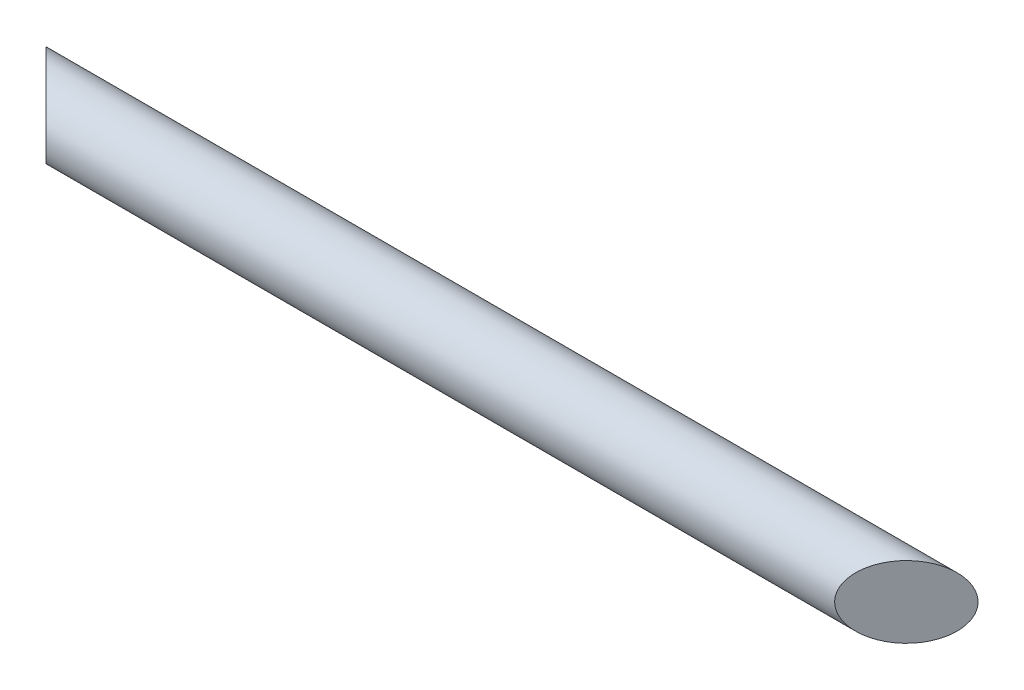
from build123d import *

# Parameters (mm, degrees)
SKETCH1_R           = 31.75
BOSS_EXTRUDE1_DEPTH = 698.5
SKETCH5_R           = 31.75
BOSS_EXTRUDE2_DEPTH = 63.5
SKETCH6_R           = 31.75
BOSS_EXTRUDE3_DEPTH = 63.5
CUT_EXTRUDE1_DEPTH  = 63.5


with BuildPart() as part:
    # Sketch1 → Boss-Extrude1 (new body)
    with BuildSketch(Plane(origin=(0, 0, 0), x_dir=(0, 0, -1), z_dir=(1, 0, 0))):
        Circle(SKETCH1_R)
    extrude(amount=BOSS_EXTRUDE1_DEPTH)

    # Sketch5 → Boss-Extrude2 (add)
    with BuildSketch(Plane.ZY):
        Circle(SKETCH5_R)
    extrude(amount=BOSS_EXTRUDE2_DEPTH)

    # Sketch6 → Boss-Extrude3 (add)
    with BuildSketch(Plane(origin=(698.5, 0, 0), x_dir=(0, 0, -1), z_dir=(1, 0, 0))):
        Circle(SKETCH6_R)
    extrude(amount=BOSS_EXTRUDE3_DEPTH)

    # Sketch7 → Cut-Extrude1 (cut)
    with BuildSketch(Plane(origin=(0, 31.75, 0), x_dir=(1, 0, 0), z_dir=(0, 1, 0))):
        Polygon((0, -31.75), (-63.5, -31.75), (-63.5, 31.75), align=None)
        Polygon((698.5, -31.75), (762, 31.75), (762, -31.75), align=None)
    extrude(amount=-CUT_EXTRUDE1_DEPTH, mode=Mode.SUBTRACT)


solid = part.part
